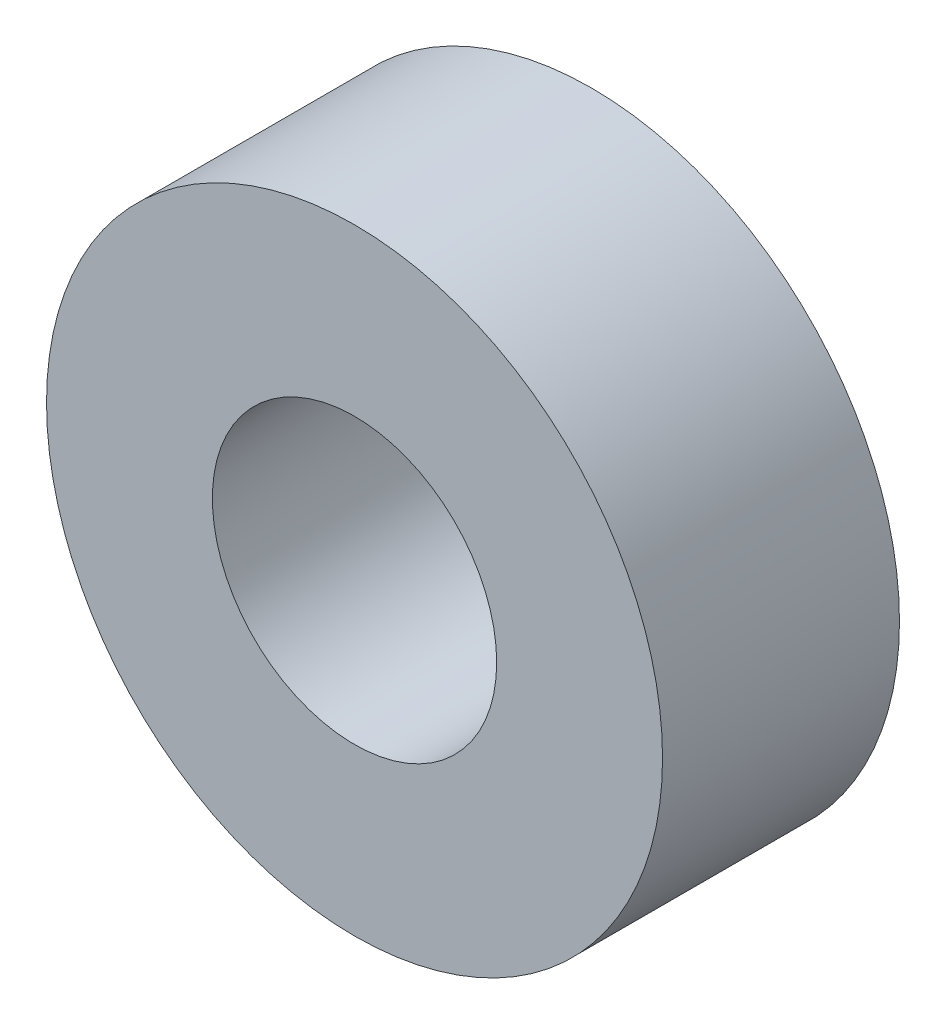
from build123d import *

# Parameters (mm, degrees)
SKETCH_1_R      = 6.5
SKETCH_1_R_2    = 3
EXTRUDE_1_DEPTH = 2.5


with BuildPart() as part:
    # 草图1 → 凸台-拉伸1 (new body, symmetric)
    with BuildSketch(Plane.XY):
        Circle(SKETCH_1_R)
        Circle(SKETCH_1_R_2, mode=Mode.SUBTRACT)
    extrude(amount=EXTRUDE_1_DEPTH, both=True)


solid = part.part
